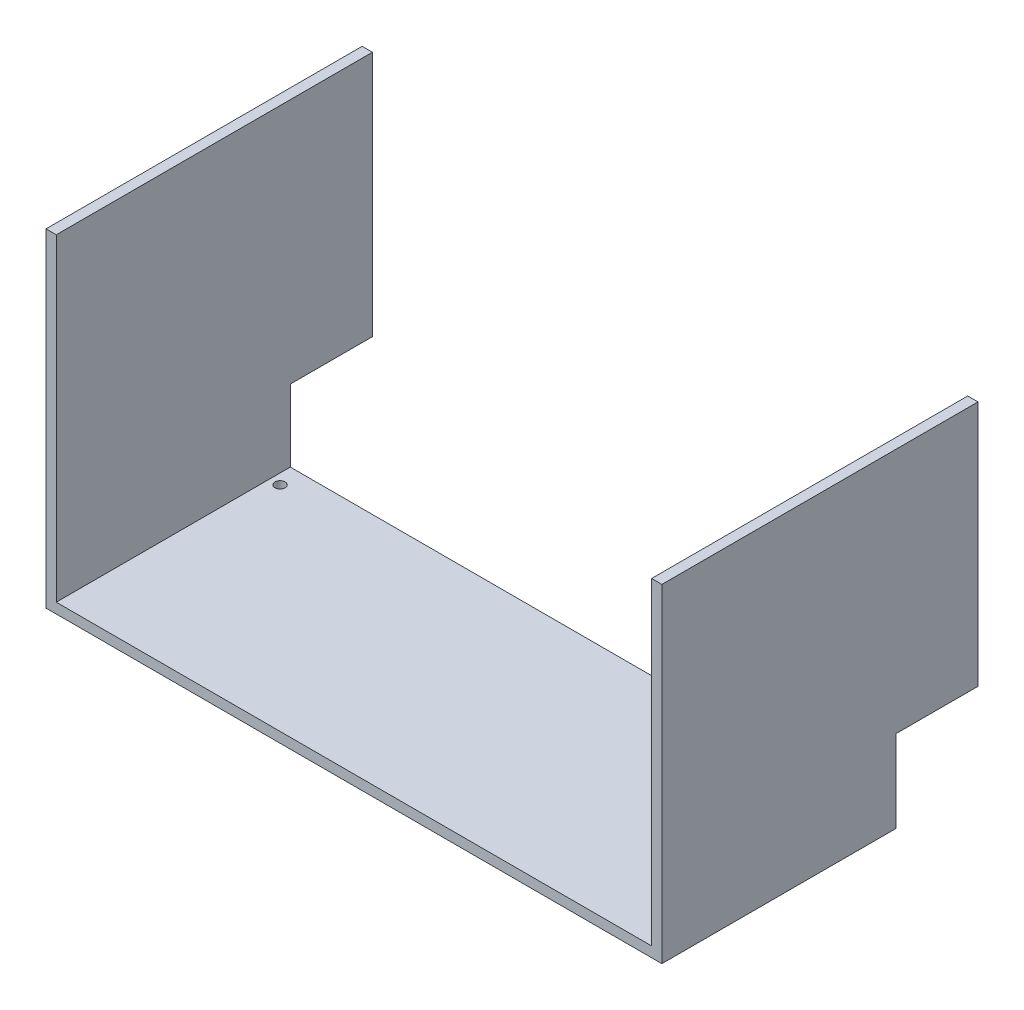
from build123d import *

# Parameters (mm, degrees)
SKETCH1_W            = 381
SKETCH1_H            = 429.26
BOSS_EXTRUDE1_DEPTH  = 6.35
SKETCH2_W            = 254
SKETCH2_H            = 203.2
CUT_EXTRUDE1_DEPTH   = 6.35
SKETCH3_W            = 381
SKETCH3_H            = 73.66
CUT_EXTRUDE2_DEPTH   = 6.35
SKETCH4_W            = 254
SKETCH4_H            = 6.35
CUT_EXTRUDE3_DEPTH   = 73.66
SKETCH6_W            = 6.35
SKETCH6_H            = 195.58
BOSS_EXTRUDE2_DEPTH  = 171.45
SKETCH7_W            = 6.35
SKETCH7_H            = 195.58
BOSS_EXTRUDE3_DEPTH  = 158.75
SKETCH8_W            = 6.35
SKETCH8_H            = 165.1
BOSS_EXTRUDE4_DEPTH  = 50.8
SKETCH9_W            = 6.35
SKETCH9_H            = 158.75
CUT_EXTRUDE4_DEPTH   = 50.8
SKETCH10_W           = 6.899940386
SKETCH10_H           = 177.8
BOSS_EXTRUDE5_DEPTH  = 50.8
SKETCH11_W           = 6.35
SKETCH11_H           = 171.45
CUT_EXTRUDE5_DEPTH   = 50.8
SKETCH13_W           = 0.549940386
SKETCH13_H           = 171.45
CUT_EXTRUDE6_DEPTH   = 50.8
SKETCH14_W           = 6.899940386
SKETCH14_H           = 177.8
CUT_EXTRUDE7_DEPTH   = 50.8
SKETCH15_W           = 6.35
SKETCH15_H           = 165.1
CUT_EXTRUDE8_DEPTH   = 50.8
SKETCH16_W           = 6.35
SKETCH16_H           = 144.78
BOSS_EXTRUDE6_DEPTH  = 25.4
SKETCH17_W           = 6.35
SKETCH17_H           = 144.78
BOSS_EXTRUDE7_DEPTH  = 19.05
SKETCH19_W           = 6.35
SKETCH19_H           = 139.7
BOSS_EXTRUDE8_DEPTH  = 50.8
SKETCH20_W           = 6.35
SKETCH20_H           = 195.58
BOSS_EXTRUDE9_DEPTH  = 31.75
SKETCH21_W           = 6.35
SKETCH21_H           = 139.7
BOSS_EXTRUDE10_DEPTH = 50.8
SKETCH22_W           = 6.35
SKETCH22_H           = 195.58
BOSS_EXTRUDE11_DEPTH = 50.8
SKETCH23_W           = 6.35
SKETCH23_H           = 50.8
BOSS_EXTRUDE12_DEPTH = 12.7
SKETCH24_W           = 6.35
SKETCH24_H           = 195.58
BOSS_EXTRUDE13_DEPTH = 12.7
SKETCH26_W           = 381
SKETCH26_H           = 210.82
CUT_EXTRUDE9_DEPTH   = 12.7
SKETCH27_R           = 3.175
CUT_EXTRUDE10_DEPTH  = 635
SKETCH28_R           = 3.175
CUT_EXTRUDE11_DEPTH  = 635


with BuildPart() as part:
    # Sketch1 → Boss-Extrude1 (new body)
    with BuildSketch(Plane(origin=(0, 0, 0), x_dir=(1, 0, 0), z_dir=(0, 1, 0))):
        with Locations((190.5, 214.63)):
            Rectangle(SKETCH1_W, SKETCH1_H)
    extrude(amount=BOSS_EXTRUDE1_DEPTH)

    # Sketch2 → Cut-Extrude1 (cut)
    with BuildSketch(Plane(origin=(0, 6.35, 0), x_dir=(1, 0, 0), z_dir=(0, 1, 0))):
        with Locations((190.5, 101.6)):
            Rectangle(SKETCH2_W, SKETCH2_H)
    extrude(amount=-CUT_EXTRUDE1_DEPTH, mode=Mode.SUBTRACT)

    # Sketch3 → Cut-Extrude2 (cut)
    with BuildSketch(Plane(origin=(0, 6.35, 0), x_dir=(1, 0, 0), z_dir=(0, 1, 0))):
        with Locations((190.5, 36.83)):
            Rectangle(SKETCH3_W, SKETCH3_H)
    extrude(amount=-CUT_EXTRUDE2_DEPTH, mode=Mode.SUBTRACT)

    # Sketch4 → Cut-Extrude3 (cut)
    with BuildSketch(Plane.XY.offset(-203.2)):
        with Locations((190.5, 3.175)):
            Rectangle(SKETCH4_W, SKETCH4_H)
    extrude(amount=-CUT_EXTRUDE3_DEPTH, mode=Mode.SUBTRACT)

    # Sketch6 → Boss-Extrude2 (add)
    with BuildSketch(Plane(origin=(0, 6.35, 0), x_dir=(1, 0, 0), z_dir=(0, 1, 0))):
        with Locations((377.825, 331.47)):
            Rectangle(SKETCH6_W, SKETCH6_H)
    extrude(amount=BOSS_EXTRUDE2_DEPTH)

    # Sketch7 → Boss-Extrude3 (add)
    with BuildSketch(Plane(origin=(0, 6.35, 0), x_dir=(1, 0, 0), z_dir=(0, 1, 0))):
        with Locations((3.175, 331.47)):
            Rectangle(SKETCH7_W, SKETCH7_H)
    extrude(amount=BOSS_EXTRUDE3_DEPTH)

    # Sketch8 → Boss-Extrude4 (add)
    with BuildSketch(Plane(origin=(0, 0, -429.26), x_dir=(-1, 0, 0), z_dir=(0, 0, -1))):
        with Locations((-3.175, 82.55)):
            Rectangle(SKETCH8_W, SKETCH8_H)
    extrude(amount=BOSS_EXTRUDE4_DEPTH)

    # Sketch9 → Cut-Extrude4 (cut)
    with BuildSketch(Plane.XY.offset(-233.68)):
        with Locations((3.175, 85.725)):
            Rectangle(SKETCH9_W, SKETCH9_H)
    extrude(amount=-CUT_EXTRUDE4_DEPTH, mode=Mode.SUBTRACT)

    # Sketch10 → Boss-Extrude5 (add)
    with BuildSketch(Plane(origin=(0, 0, -429.26), x_dir=(-1, 0, 0), z_dir=(0, 0, -1))):
        with Locations((-377.550029807, 88.9)):
            Rectangle(SKETCH10_W, SKETCH10_H)
    extrude(amount=BOSS_EXTRUDE5_DEPTH)

    # Sketch11 → Cut-Extrude5 (cut)
    with BuildSketch(Plane.XY.offset(-233.68)):
        with Locations((377.825, 92.075)):
            Rectangle(SKETCH11_W, SKETCH11_H)
    extrude(amount=-CUT_EXTRUDE5_DEPTH, mode=Mode.SUBTRACT)

    # Sketch13 → Cut-Extrude6 (cut)
    with BuildSketch(Plane.XY.offset(-429.26)):
        with Locations((374.375029807, 92.075)):
            Rectangle(SKETCH13_W, SKETCH13_H)
    extrude(amount=-CUT_EXTRUDE6_DEPTH, mode=Mode.SUBTRACT)

    # Sketch14 → Cut-Extrude7 (cut)
    with BuildSketch(Plane(origin=(0, 0, -480.06), x_dir=(-1, 0, 0), z_dir=(0, 0, -1))):
        with Locations((-377.550029807, 88.9)):
            Rectangle(SKETCH14_W, SKETCH14_H)
    extrude(amount=-CUT_EXTRUDE7_DEPTH, mode=Mode.SUBTRACT)

    # Sketch15 → Cut-Extrude8 (cut)
    with BuildSketch(Plane(origin=(0, 0, -480.06), x_dir=(-1, 0, 0), z_dir=(0, 0, -1))):
        with Locations((-3.175, 82.55)):
            Rectangle(SKETCH15_W, SKETCH15_H)
    extrude(amount=-CUT_EXTRUDE8_DEPTH, mode=Mode.SUBTRACT)

    # Sketch16 → Boss-Extrude6 (add)
    with BuildSketch(Plane(origin=(0, 177.8, 0), x_dir=(1, 0, 0), z_dir=(0, 1, 0))):
        with Locations((377.825, 356.87)):
            Rectangle(SKETCH16_W, SKETCH16_H)
    extrude(amount=BOSS_EXTRUDE6_DEPTH)

    # Sketch17 → Boss-Extrude7 (add)
    with BuildSketch(Plane(origin=(0, 165.1, 0), x_dir=(1, 0, 0), z_dir=(0, 1, 0))):
        with Locations((3.175, 356.87)):
            Rectangle(SKETCH17_W, SKETCH17_H)
    extrude(amount=-BOSS_EXTRUDE7_DEPTH)

    # Sketch19 → Boss-Extrude8 (add)
    with BuildSketch(Plane(origin=(0, 0, -429.26), x_dir=(-1, 0, 0), z_dir=(0, 0, -1))):
        with Locations((-3.175, 120.65)):
            Rectangle(SKETCH19_W, SKETCH19_H)
    extrude(amount=BOSS_EXTRUDE8_DEPTH)

    # Sketch20 → Boss-Extrude9 (add)
    with BuildSketch(Plane(origin=(0, 190.5, 0), x_dir=(1, 0, 0), z_dir=(0, 1, 0))):
        with Locations((3.175, 382.27)):
            Rectangle(SKETCH20_W, SKETCH20_H)
    extrude(amount=-BOSS_EXTRUDE9_DEPTH)

    # Sketch21 → Boss-Extrude10 (add)
    with BuildSketch(Plane(origin=(0, 0, -429.26), x_dir=(-1, 0, 0), z_dir=(0, 0, -1))):
        with Locations((-377.825, 133.35)):
            Rectangle(SKETCH21_W, SKETCH21_H)
    extrude(amount=BOSS_EXTRUDE10_DEPTH)

    # Sketch22 → Boss-Extrude11 (add)
    with BuildSketch(Plane(origin=(0, 203.2, 0), x_dir=(1, 0, 0), z_dir=(0, 1, 0))):
        with Locations((377.825, 382.27)):
            Rectangle(SKETCH22_W, SKETCH22_H)
    extrude(amount=-BOSS_EXTRUDE11_DEPTH)

    # Sketch23 → Boss-Extrude12 (add)
    with BuildSketch(Plane.XZ.offset(-63.5)):
        with Locations((377.825, -454.66)):
            Rectangle(SKETCH23_W, SKETCH23_H)
    extrude(amount=BOSS_EXTRUDE12_DEPTH)

    # Sketch24 → Boss-Extrude13 (add)
    with BuildSketch(Plane(origin=(0, 190.5, 0), x_dir=(1, 0, 0), z_dir=(0, 1, 0))):
        with Locations((3.175, 382.27)):
            Rectangle(SKETCH24_W, SKETCH24_H)
    extrude(amount=BOSS_EXTRUDE13_DEPTH)

    # Sketch26 → Cut-Extrude9 (cut)
    with BuildSketch(Plane(origin=(0, 6.35, 0), x_dir=(1, 0, 0), z_dir=(0, 1, 0))):
        with Locations((190.5, 179.07)):
            Rectangle(SKETCH26_W, SKETCH26_H)
    extrude(amount=-CUT_EXTRUDE9_DEPTH, mode=Mode.SUBTRACT)

    # Sketch27 → Cut-Extrude10 (cut)
    with BuildSketch(Plane(origin=(0, 6.35, 0), x_dir=(1, 0, 0), z_dir=(0, 1, 0))):
        with Locations((368.3, 416.56)):
            Circle(SKETCH27_R)
    extrude(amount=-CUT_EXTRUDE10_DEPTH, mode=Mode.SUBTRACT)

    # Sketch28 → Cut-Extrude11 (cut)
    with BuildSketch(Plane(origin=(0, 6.35, 0), x_dir=(1, 0, 0), z_dir=(0, 1, 0))):
        with Locations((12.7, 416.56)):
            Circle(SKETCH28_R)
    extrude(amount=-CUT_EXTRUDE11_DEPTH, mode=Mode.SUBTRACT)


solid = part.part
